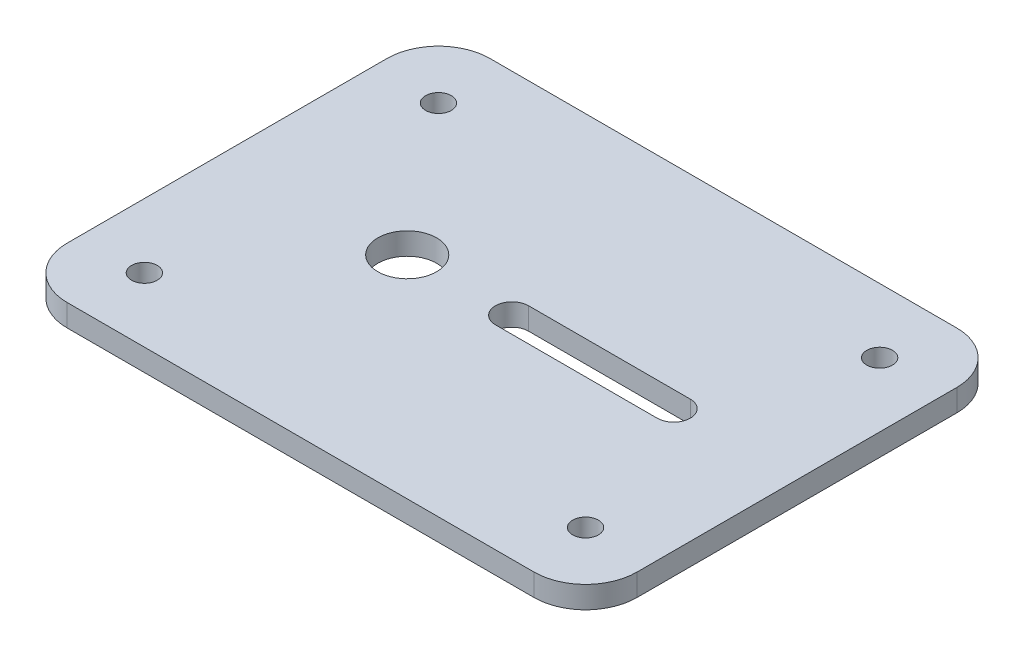
from build123d import *

# Parameters (mm, degrees)
SKETCH_1_W                  = 104.137931034
SKETCH_1_H                  = 70
EXTRUDE_1_DEPTH             = 3
SKETCH_2_R                  = 1.75
CUT_EXTRUDE_1_DEPTH         = 10
PATTERN_LINEAR_1_COUNT      = 2
PATTERN_LINEAR_1_PITCH      = 60
PATTERN_LINEAR_1_COUNT_DIR2 = 2
PATTERN_LINEAR_1_PITCH_DIR2 = 40
CUT_EXTRUDE_2_DEPTH         = 4
SKETCH_4_R                  = 4
CUT_EXTRUDE_3_DEPTH         = 4
FILLET_1_R                  = 7


with BuildPart() as part:
    # Эскиз1 → Бобышка-Вытянуть1 (new body)
    with BuildSketch(Plane(origin=(0, 0, 0), x_dir=(1, 0, 0), z_dir=(0, 1, 0))):
        Rectangle(SKETCH_1_W, SKETCH_1_H)
    extrude(amount=EXTRUDE_1_DEPTH)

    # Эскиз2 → Вырез-Вытянуть1 (cut)
    with BuildSketch(Plane(origin=(0, 3, 0), x_dir=(1, 0, 0), z_dir=(0, 1, 0))):
        with Locations((-43.318965517, 26.25)):
            Circle(SKETCH_2_R)
    cut_extrude_1 = extrude(amount=-CUT_EXTRUDE_1_DEPTH, mode=Mode.SUBTRACT)

    # Линейный массив1: Cut-Extrude 1 2 × 2
    with Locations(*[(i * PATTERN_LINEAR_1_PITCH, 0, j * PATTERN_LINEAR_1_PITCH_DIR2) for i in range(PATTERN_LINEAR_1_COUNT) for j in range(PATTERN_LINEAR_1_COUNT_DIR2) if (i, j) != (0, 0)]):
        add(cut_extrude_1, mode=Mode.SUBTRACT)

    # Эскиз3 → Вырез-Вытянуть2 (cut, through all)
    with BuildSketch(Plane(origin=(0, 3, 0), x_dir=(1, 0, 0), z_dir=(0, 1, 0))):
        Polygon((-52.068965517, -22.5), (25.431034483, -22.5), (25.431034483, 35), (52.068965517, 35), (52.068965517, -35), (-52.068965517, -35), align=None)
    extrude(amount=-CUT_EXTRUDE_2_DEPTH, mode=Mode.SUBTRACT)

    # Эскиз4 → Вырез-Вытянуть3 (cut, through all)
    with BuildSketch(Plane(origin=(0, 3, 0), x_dir=(1, 0, 0), z_dir=(0, 1, 0))):
        with Locations((-27.568965517, 6.25)):
            Circle(SKETCH_4_R)
        with BuildLine():
            Line((-13.318965517, 8.5), (8.681034483, 8.5))
            ThreePointArc((8.681034483, 8.5), (10.931034483, 6.25), (8.681034483, 4))
            Line((8.681034483, 4), (-13.318965517, 4))
            ThreePointArc((-13.318965517, 4), (-15.568965517, 6.25), (-13.318965517, 8.5))
        make_face()
    extrude(amount=-CUT_EXTRUDE_3_DEPTH, mode=Mode.SUBTRACT)

    # Скругление1
    fillet_1_edges = [part.edges().sort_by_distance(p)[0] for p in [
        (-52.068965517, 1.5, 22.5),
        (25.431034483, 1.5, 22.5),
        (25.431034483, 1.5, -35),
        (-52.068965517, 1.5, -35),
    ]]
    fillet(fillet_1_edges, radius=FILLET_1_R)


solid = part.part
